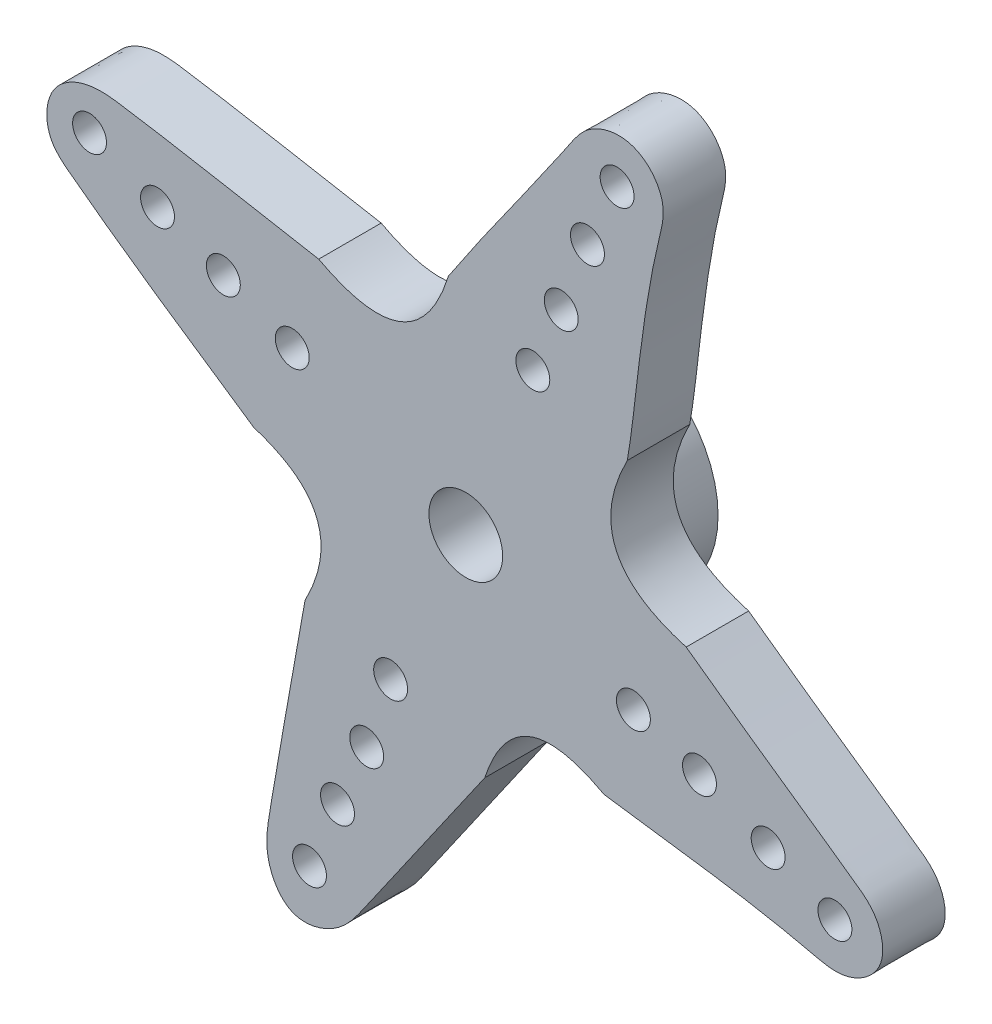
from build123d import *

# Parameters (mm, degrees)
ESQUISSE1_R        = 1.5
ESQUISSE1_R_2      = 0.689564765
BOSS_EXTRU_4_DEPTH = 2.54
BOSS_EXTRU_7_START = -3.28
ESQUISSE1_7_R      = 4.44
ESQUISSE1_7_R_2    = 1.5
BOSS_EXTRU_7_DEPTH = 3.28


with BuildPart() as part:
    # Esquisse1 → Boss.-Extru.4 (new body)
    with BuildSketch(Plane.XY):
        with BuildLine():
            add(Edge.make_bspline(
                [(6.567121495, 5.905433908), (4.461837226, 1.828122654), (8.962742331, 0.533193532)],
                knots=[0, 0, 0, 1, 1, 1], degree=2))
            add(Edge.make_bspline(
                [(8.962742331, 0.533193532), (11.233599128, -1.135170693), (13.794278142, -2.872025716), (16.804742935, -5.019945798), (17.24049157, -6.879111238), (15.533969393, -8.053949097), (11.459274334, -7.032983025), (8.254762212, -6.729080876), (5.625829249, -6.329345715)],
                knots=[0, 0, 0, 0, 0.365230702, 0.413690239, 0.484595372, 0.573039448, 0.624579911, 1, 1, 1, 1], degree=3))
            add(Edge.make_bspline(
                [(5.625829249, -6.329345715), (2.024885254, -4.344149707), (0.77159782, -8.16692335)],
                knots=[0, 0, 0, 1, 1, 1], degree=2))
            add(Edge.make_bspline(
                [(0.77159782, -8.16692335), (-1.498537108, -11.40585955), (-2.572114914, -12.991594751), (-5.134867914, -16.635392391), (-7.248385516, -17.326519985), (-8.234579565, -15.384075376), (-7.560702293, -11.154226456), (-7.169038126, -9.21402013), (-6.538213987, -5.57486786)],
                knots=[0, 0, 0, 0, 0.370191432, 0.421116934, 0.50925502, 0.593777603, 0.642852101, 1, 1, 1, 1], degree=3))
            add(Edge.make_bspline(
                [(-6.538213987, -5.57486786), (-4.548409588, -1.790797747), (-8.62512041, -0.523225883)],
                knots=[0, 0, 0, 1, 1, 1], degree=2))
            add(Edge.make_bspline(
                [(-8.62512041, -0.523225883), (-12.091510063, 1.825480591), (-13.655654454, 2.851972586), (-17.125018828, 5.462898262), (-17.083003107, 7.517905935), (-15.386738158, 8.351959165), (-11.092119748, 7.679282599), (-8.699281787, 7.195059354), (-5.980588442, 6.723763978)],
                knots=[0, 0, 0, 0, 0.388587579, 0.43995622, 0.513686408, 0.605056424, 0.653687784, 1, 1, 1, 1], degree=3))
            add(Edge.make_bspline(
                [(-0.703210078, 8.768050227), (-2.008627705, 4.605601266), (-5.980588442, 6.723763978)],
                knots=[0, 0, 0, 1, 1, 1], degree=2))
            add(Edge.make_bspline(
                [(-0.703210078, 8.768050227), (1.038103991, 11.414566676), (2.726327809, 13.600182572), (4.985759508, 17.028699407), (6.944996298, 17.475743013), (8.249239792, 15.842036451), (7.123741289, 11.666529445), (6.912796091, 7.795610598), (6.567121495, 5.905433908)],
                knots=[0, 0, 0, 0, 0.368171065, 0.418118472, 0.499474066, 0.581227244, 0.631279838, 1, 1, 1, 1], degree=3))
        make_face()
        Circle(ESQUISSE1_R, mode=Mode.SUBTRACT)
        with Locations((-3.055730452, -6.615695246)):
            Circle(ESQUISSE1_R_2, mode=Mode.SUBTRACT)
        with Locations((6.81646767, -2.750390202)):
            Circle(ESQUISSE1_R_2, mode=Mode.SUBTRACT)
        with Locations((9.503806951, -3.694002797)):
            Circle(ESQUISSE1_R_2, mode=Mode.SUBTRACT)
        with Locations((12.296421164, -4.867858313)):
            Circle(ESQUISSE1_R_2, mode=Mode.SUBTRACT)
        with Locations((15.011032301, -6.044747963)):
            Circle(ESQUISSE1_R_2, mode=Mode.SUBTRACT)
        with Locations((2.725885646, 7.16635514)):
            Circle(ESQUISSE1_R_2, mode=Mode.SUBTRACT)
        with Locations((3.882079968, 9.873073051)):
            Circle(ESQUISSE1_R_2, mode=Mode.SUBTRACT)
        with Locations((4.948281002, 12.700823619)):
            Circle(ESQUISSE1_R_2, mode=Mode.SUBTRACT)
        with Locations((6.153551735, 15.34314792)):
            Circle(ESQUISSE1_R_2, mode=Mode.SUBTRACT)
        with Locations((-4.029330045, -9.482405157)):
            Circle(ESQUISSE1_R_2, mode=Mode.SUBTRACT)
        with Locations((-5.215661817, -12.096838797)):
            Circle(ESQUISSE1_R_2, mode=Mode.SUBTRACT)
        with Locations((-6.355151293, -14.837202916)):
            Circle(ESQUISSE1_R_2, mode=Mode.SUBTRACT)
        with Locations((-7.057369503, 3.055488218)):
            Circle(ESQUISSE1_R_2, mode=Mode.SUBTRACT)
        with Locations((-9.859225558, 4.216302275)):
            Circle(ESQUISSE1_R_2, mode=Mode.SUBTRACT)
        with Locations((-12.535767353, 5.279634897)):
            Circle(ESQUISSE1_R_2, mode=Mode.SUBTRACT)
        with Locations((-15.299960499, 6.510661118)):
            Circle(ESQUISSE1_R_2, mode=Mode.SUBTRACT)
    extrude(amount=BOSS_EXTRU_4_DEPTH)

    # Esquisse1_7 → Boss.-Extru.7 (add)
    with BuildSketch(Plane.XY.offset(BOSS_EXTRU_7_START)):
        Circle(ESQUISSE1_7_R)
        Circle(ESQUISSE1_7_R_2, mode=Mode.SUBTRACT)
    extrude(amount=BOSS_EXTRU_7_DEPTH)


solid = part.part
